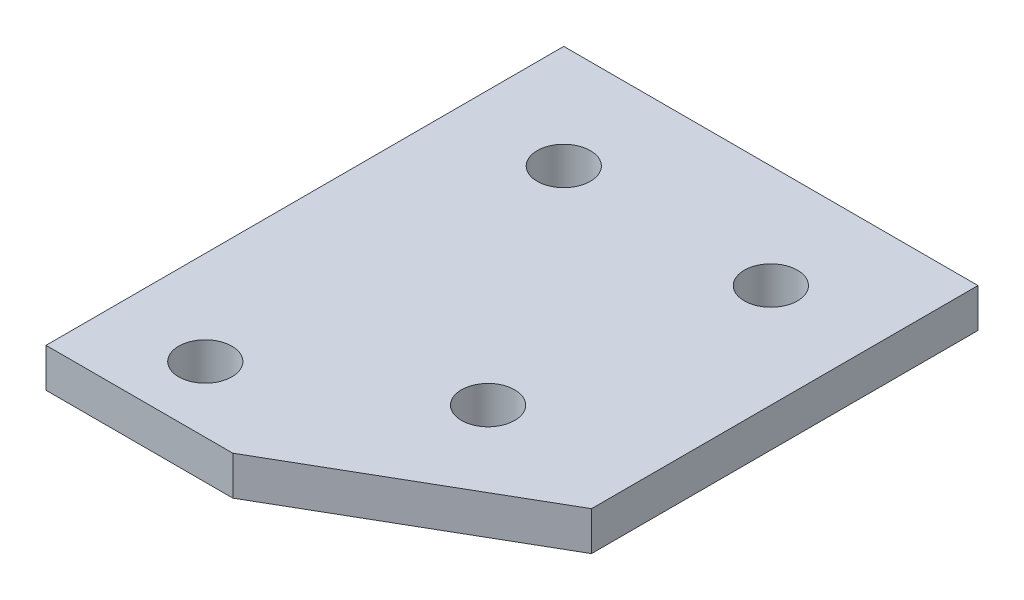
from build123d import *

# Parameters (mm, degrees)
SKETCH1_R           = 3.2639
BOSS_EXTRUDE1_DEPTH = 4.7752


with BuildPart() as part:
    # Sketch1 (on Top Plane) → Boss-Extrude1 (new body)
    with BuildSketch(Plane(origin=(0, 0, 0), x_dir=(1, 0, 0), z_dir=(0, 1, 0))):
        Polygon((50.8, -47.3964), (50.8, 0), (0, 0), (0, -63.5), (22.907746615, -63.5), align=None)
        with Locations(Location((11.48588, -55.45328, 0), (0, 0, 90))):
            Circle(SKETCH1_R, mode=Mode.SUBTRACT)
        with Locations(Location((33.45942, -42.74312, 0), (0, 0, 90))):
            Circle(SKETCH1_R, mode=Mode.SUBTRACT)
        with Locations(Location((38.1, -12.7, 0), (0, 0, 90))):
            Circle(SKETCH1_R, mode=Mode.SUBTRACT)
        with Locations(Location((12.7, -12.7, 0), (0, 0, 90))):
            Circle(SKETCH1_R, mode=Mode.SUBTRACT)
    extrude(amount=-BOSS_EXTRUDE1_DEPTH)


solid = part.part
